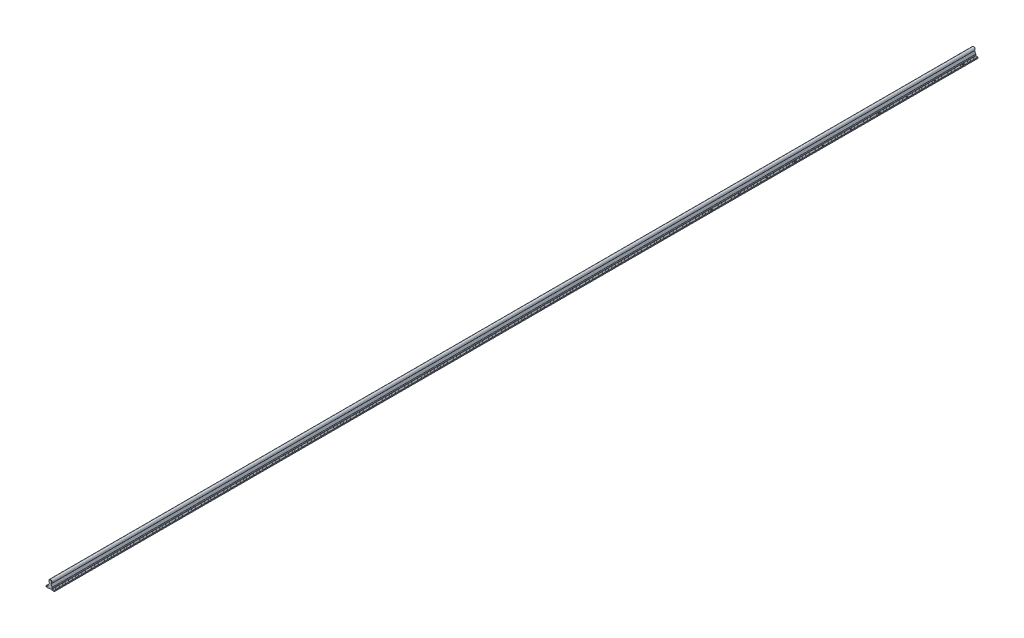
from build123d import *

# Parameters (mm, degrees)
BOSS_EXTRU_1_DEPTH         = 3300
CHANFREIN5_SIZE            = 1
CHANFREIN6_SIZE            = 1
ENL_V_START                = -4
ESQUISSE2_R                = 2.25
ENL_V_MAT_EXTRU_1_DEPTH    = 4
R_P_TITION_LIN_AIRE1_COUNT = 9
R_P_TITION_LIN_AIRE1_PITCH = 100


with BuildPart() as part:
    # Esquisse1 → Boss.-Extru.1 (new body)
    with BuildSketch(Plane.XY):
        with BuildLine():
            Line((0, 0), (0, 3.5))
            ThreePointArc((0, 3.5), (0.146446609, 3.853553391), (0.5, 4))
            Line((0.5, 4), (3.9, 4))
            Line((3.9, 4), (3.9, 3.8))
            Line((3.9, 3.8), (4.1, 3.8))
            Line((4.1, 3.8), (4.1, 4))
            Line((4.1, 4), (7.5, 4))
            ThreePointArc((7.5, 4), (7.853553391, 4.146446609), (8, 4.5))
            Line((8, 4.5), (8, 8.885625558))
            ThreePointArc((8, 8.885625558), (8.012589542, 8.997120156), (8.049724182, 9.103000091))
            Line((8.049724182, 9.103000091), (12.391505605, 18.096690182))
            ThreePointArc((12.391505605, 18.096690182), (15, 29.5), (17.608494395, 18.096690182))
            Line((17.608494395, 18.096690182), (21.950275818, 9.103000091))
            ThreePointArc((21.950275818, 9.103000091), (21.987410458, 8.997120156), (22, 8.885625558))
            Line((22, 8.885625558), (22, 4.5))
            ThreePointArc((22, 4.5), (22.146446609, 4.146446609), (22.5, 4))
            Line((22.5, 4), (25.9, 4))
            Line((25.9, 4), (25.9, 3.8))
            Line((25.9, 3.8), (26.1, 3.8))
            Line((26.1, 3.8), (26.1, 4))
            Line((26.1, 4), (29.5, 4))
            ThreePointArc((29.5, 4), (29.853553391, 3.853553391), (30, 3.5))
            Line((30, 3.5), (30, 0))
            Line((30, 0), (19, 0))
            Line((19, 0), (19, 0.5))
            ThreePointArc((19, 0.5), (18.853553391, 0.853553391), (18.5, 1))
            Line((18.5, 1), (11.5, 1))
            ThreePointArc((11.5, 1), (11.146446609, 0.853553391), (11, 0.5))
            Line((11, 0.5), (11, 0))
            Line((11, 0), (0, 0))
        make_face()
    extrude(amount=BOSS_EXTRU_1_DEPTH)

    # Chanfrein5
    chanfrein5_edges = [part.edges().sort_by_distance(p)[0] for p in [
        (15, 29.5, 0),
    ]]
    chamfer(chanfrein5_edges, length=CHANFREIN5_SIZE)

    # Chanfrein6
    chanfrein6_edges = [part.edges().sort_by_distance(p)[0] for p in [
        (15, 29.5, 3300),
    ]]
    chamfer(chanfrein6_edges, length=CHANFREIN6_SIZE)

    # Esquisse2 → Enlèv. mat.-Extru.1 (cut)
    with BuildSketch(Plane.XZ.offset(ENL_V_START)):
        with Locations((4, 850)):
            Circle(ESQUISSE2_R)
        with Locations((26, 850)):
            Circle(ESQUISSE2_R)
        with Locations((26, 950)):
            Circle(ESQUISSE2_R)
        with Locations((4, 950)):
            Circle(ESQUISSE2_R)
    enl_v_mat_extru_1 = extrude(amount=ENL_V_MAT_EXTRU_1_DEPTH, mode=Mode.SUBTRACT)

    # Répétition linéaire1: Enlèv. mat.-Extru.1 ×9
    with Locations(*[(0, 0, -i * R_P_TITION_LIN_AIRE1_PITCH) for i in range(1, R_P_TITION_LIN_AIRE1_COUNT)]):
        add(enl_v_mat_extru_1, mode=Mode.SUBTRACT)


solid = part.part
